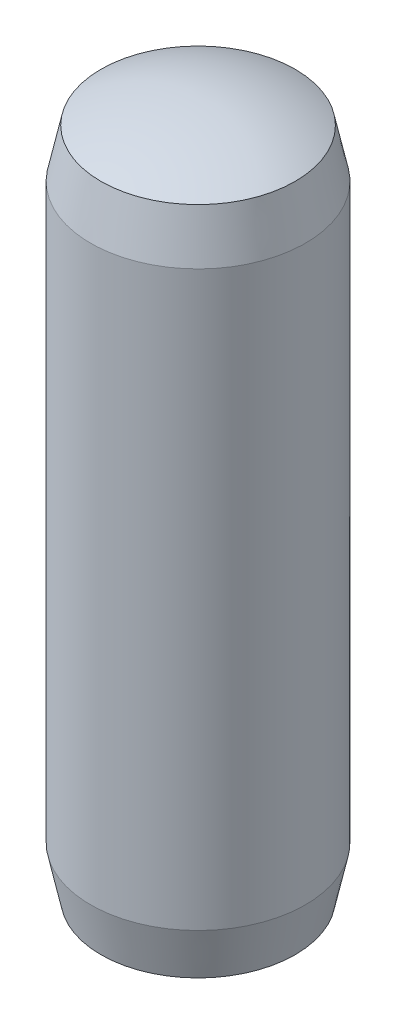
from build123d import *

# Parameters (mm, degrees)
SKETCH1_R           = 0.75
BOSS_EXTRUDE1_DEPTH = 5


with BuildPart() as part:
    # Sketch1 → Boss-Extrude1 (new body)
    with BuildSketch(Plane(origin=(0, 0, 0), x_dir=(1, 0, 0), z_dir=(0, 1, 0))):
        Circle(SKETCH1_R)
    extrude(amount=BOSS_EXTRUDE1_DEPTH)

    # Sketch2 → Cut-Revolve2 (revolve, cut)
    with BuildSketch(Plane.XY):
        with BuildLine():
            Line((0.75, 4.799038106), (0.75, 5.1))
            Line((0.75, 5.1), (0, 5.1))
            Line((0, 5.1), (0, 5))
            ThreePointArc((0, 5), (0.388228568, 4.948888739), (0.75, 4.799038106))
        make_face()
        with BuildLine():
            Line((0.75, -0.1), (0, -0.1))
            Line((0, -0.1), (0, 0))
            ThreePointArc((0, 0), (0.388228568, 0.051111261), (0.75, 0.200961894))
            Line((0.75, 0.200961894), (0.75, -0.1))
        make_face()
    revolve(axis=Axis((0, 0, 0), (0, 1, 0)), mode=Mode.SUBTRACT)

    # Sketch3 → Cut-Revolve3 (revolve, cut)
    with BuildSketch(Plane.XY):
        with BuildLine():
            Line((-0.75, 4.5), (-0.678168292, 4.837941616))
            ThreePointArc((-0.678168292, 4.837941616), (-0.714349031, 4.818978947), (-0.75, 4.799038106))
            Line((-0.75, 4.799038106), (-0.75, 4.5))
        make_face()
        with BuildLine():
            Line((-0.75, 0.200961894), (-0.75, 0.5))
            Line((-0.75, 0.5), (-0.678168292, 0.162058384))
            ThreePointArc((-0.678168292, 0.162058384), (-0.714349031, 0.181021053), (-0.75, 0.200961894))
        make_face()
    revolve(axis=Axis((0, 0, 0), (0, 1, 0)), mode=Mode.SUBTRACT)


solid = part.part
